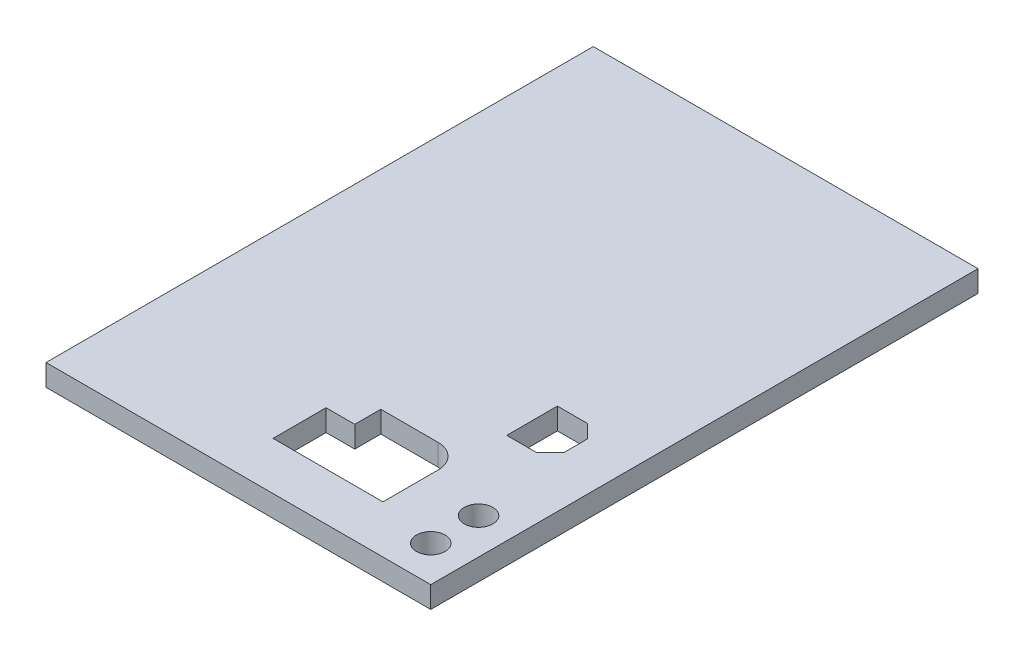
from build123d import *

# Parameters (mm, degrees)
SKETCH1_W           = 161
SKETCH1_H           = 229
BOSS_EXTRUDE1_DEPTH = 9
SKETCH2_R           = 6
CUT_EXTRUDE1_DEPTH  = 10


with BuildPart() as part:
    # Sketch1 → Boss-Extrude1 (new body)
    with BuildSketch(Plane(origin=(0, 0, 0), x_dir=(1, 0, 0), z_dir=(0, 1, 0))):
        Rectangle(SKETCH1_W, SKETCH1_H)
    extrude(amount=BOSS_EXTRUDE1_DEPTH)

    # Sketch2 → Cut-Extrude1 (cut, through all)
    with BuildSketch(Plane(origin=(0, 9, 0), x_dir=(1, 0, 0), z_dir=(0, 1, 0))):
        with Locations((65.5, -99.5)):
            Circle(SKETCH2_R)
        with Locations((65.5, -79.5)):
            Circle(SKETCH2_R)
        with BuildLine():
            Line((40.5, -94.5), (-5.5, -94.5))
            Line((-5.5, -94.5), (-5.5, -72.3))
            Line((-5.5, -72.3), (6.5, -72.3))
            Line((6.5, -72.3), (6.5, -61.4))
            Line((6.5, -61.4), (30.5, -61.4))
            ThreePointArc((30.5, -61.4), (37.571067812, -64.328932188), (40.5, -71.4))
            Line((40.5, -71.4), (40.5, -94.5))
        make_face()
        Polygon((42.3, -23.3), (54.9, -23.3), (60.5, -28.9), (60.5, -38.9), (54.9, -44.5), (42.3, -44.5), align=None)
    extrude(amount=-CUT_EXTRUDE1_DEPTH, mode=Mode.SUBTRACT)


solid = part.part
